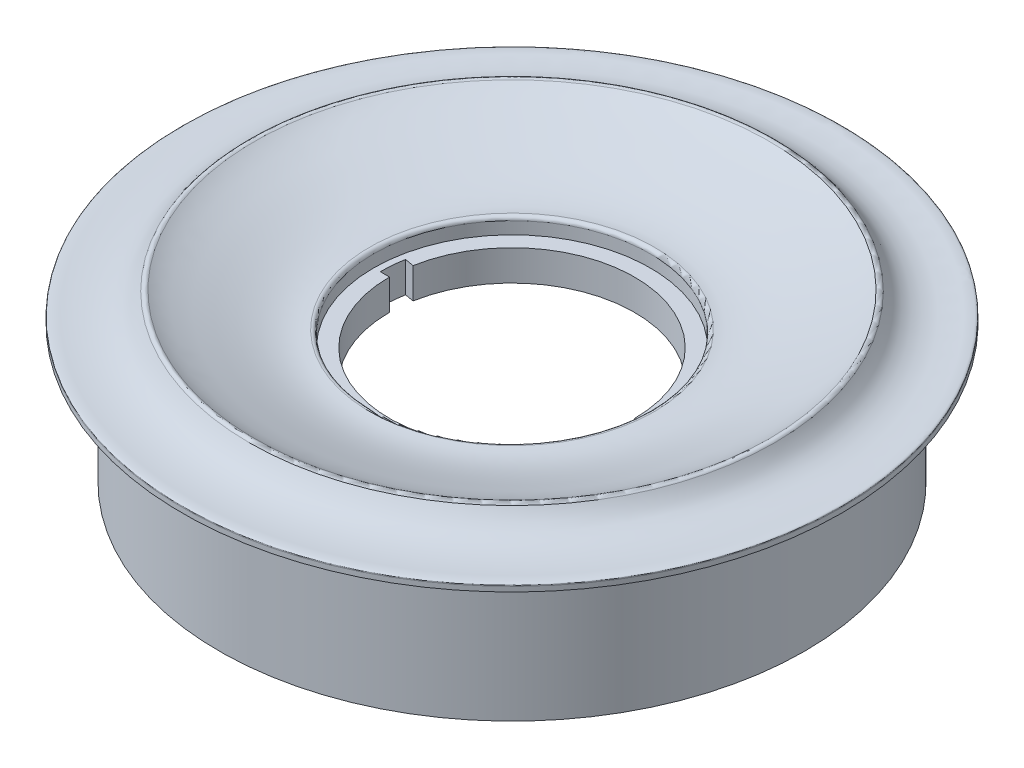
from build123d import *

# Parameters (mm, degrees)
CUT_EXTRUDE2_DEPTH = 25.4


with BuildPart() as part:
    # Sketch1 → Revolve1 (revolve)
    with BuildSketch(Plane.XY):
        with BuildLine():
            add(Edge.make_bspline(
                [(54.433417298, 16.49239871), (55.140329388, 15.400801012), (56.634122685, 13.453380309), (61.08498084, 11.924532968), (65.046523373, 12.153974865), (67.358695697, 12.33292583), (68.25556097, 12.181396929), (68.301651302, 11.985609278)],
                knots=[0.03248383, 0.03248383, 0.03248383, 0.03248383, 0.240160522, 0.498483462, 0.829405314, 0.925193367, 0.958836687, 0.958836687, 0.958836687, 0.958836687], degree=3))
            ThreePointArc((68.301651302, 11.985609278), (68.31684077, 11.898891248), (68.321926556, 11.811))
            Line((68.321926556, 11.811), (68.321926556, 10.795))
            Line((68.321926556, 10.795), (60.701926556, 10.795))
            Line((60.701926556, 10.795), (60.701926556, -17.78))
            Line((60.701926556, -17.78), (59.177926556, -17.78))
            Line((59.177926556, -17.78), (59.177926556, 10.16))
            Line((59.177926556, 10.16), (52.950581982, 15.081797011))
            Line((52.950581982, 15.081797011), (31.75, 7.62))
            Line((31.75, 7.62), (31.75, 3.81))
            Line((31.75, 3.81), (27.94, 3.81))
            Line((27.94, 3.81), (27.94, 0))
            Line((27.94, 0), (25.4, 0))
            Line((25.4, 0), (25.4, 6.35))
            Line((25.4, 6.35), (28.670175306, 6.35))
            Line((28.670175306, 6.35), (28.670175306, 8.89))
            ThreePointArc((28.670175306, 8.89), (28.928437505, 9.461744898), (29.528160156, 9.645930492))
            add(Edge.make_bspline(
                [(29.528160156, 9.645930492), (32.354832615, 9.287011602), (37.800838373, 10.300025022), (43.811619933, 12.513834286), (48.971482967, 14.425435391), (51.771997956, 15.651205638), (53.372535634, 16.713150898)],
                knots=[0.030765862, 0.030765862, 0.030765862, 0.030765862, 0.353803291, 0.633803769, 0.758492975, 0.975529833, 0.975529833, 0.975529833, 0.975529833], degree=3))
            ThreePointArc((53.372535634, 16.713150898), (53.949055653, 16.824220242), (54.433417298, 16.49239871))
        make_face()
    revolve(axis=Axis((0, -26.858783784, 0), (0, 1, 0)))

    # Sketch2 → Cut-Extrude2 (cut)
    with BuildSketch(Plane(origin=(0, 6.35, 0), x_dir=(1, 0, 0), z_dir=(0, 1, 0))):
        with BuildLine():
            ThreePointArc((26.876373604, -4.819083617), (27.197632307, -2.419053921), (27.305, 0))
            Line((27.305, 0), (25.4, 0))
            ThreePointArc((25.4, 0), (25.300123077, -2.250282718), (25.001277771, -4.482868481))
            Line((25.001277771, -4.482868481), (26.876373604, -4.819083617))
        make_face()
        with BuildLine():
            Line((-25.001277771, 4.482868481), (-26.876373604, 4.819083617))
            ThreePointArc((-26.876373604, 4.819083617), (-27.197632307, 2.419053921), (-27.305, 0))
            Line((-27.305, 0), (-25.4, 0))
            ThreePointArc((-25.4, 0), (-25.300123077, 2.250282718), (-25.001277771, 4.482868481))
        make_face()
    extrude(amount=-CUT_EXTRUDE2_DEPTH, mode=Mode.SUBTRACT)


solid = part.part
